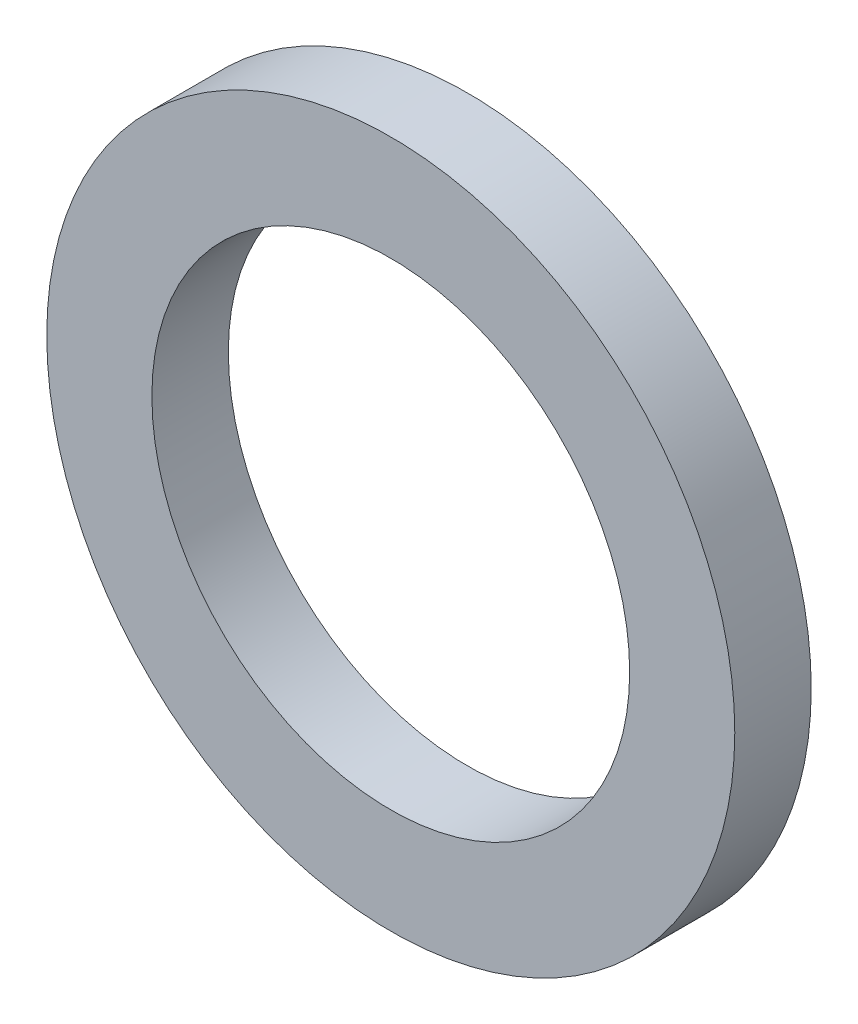
from build123d import *

# Parameters (mm, degrees)
SKETCH1_R           = 18
SKETCH1_R_2         = 12.5
BOSS_EXTRUDE1_DEPTH = 4


with BuildPart() as part:
    # Sketch1 → Boss-Extrude1 (new body)
    with BuildSketch(Plane.XY):
        Circle(SKETCH1_R)
        Circle(SKETCH1_R_2, mode=Mode.SUBTRACT)
    extrude(amount=BOSS_EXTRUDE1_DEPTH)


solid = part.part
